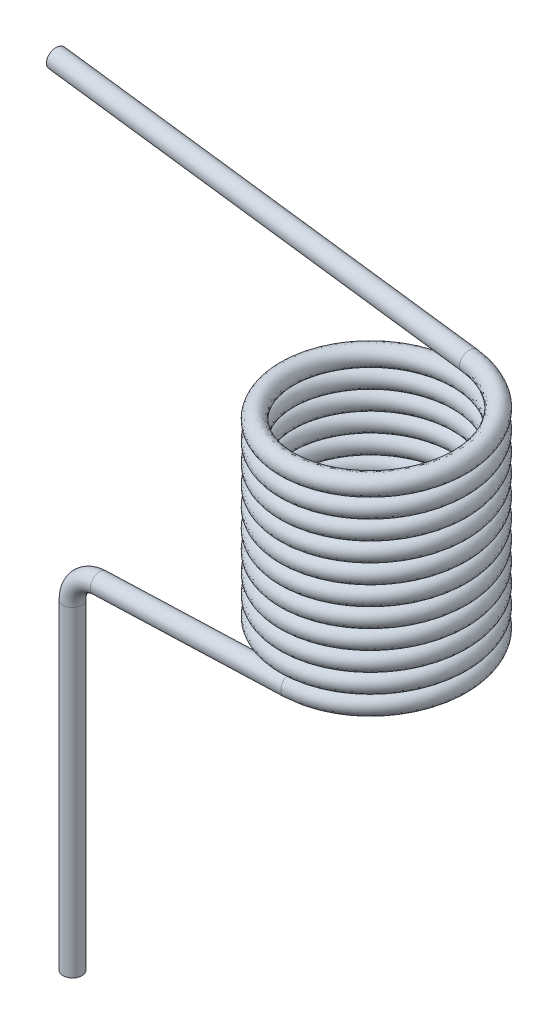
from build123d import *

# Parameters (mm, degrees)
SKETCH5_R = 0.127


with BuildPart() as part:
    # Sweep4: sweep along a curve in space
    with BuildLine() as sweep4_path:
        Line((-2.921, -4.7752, 1.1557), (-2.921, -0.470198244, 1.1557))
        ThreePointArc((-2.921, -0.470198244, 1.1557), (-2.814082298, -0.20554773, 1.1557), (-2.553336514, -0.089431731, 1.1557))
        Line((-2.553336514, -0.089431731, 1.1557), (0, 0, 1.1557))
        add(Edge.make_bspline(
            [(0, 0, 1.1557), (0.151002766, 0.005288938, 1.1557), (0.456339858, 0.015986032, 1.094955778), (0.841622203, 0.03193584, 0.835606243), (1.098293697, 0.047911326, 0.447870961), (1.186031785, 0.063879932, -0.008676931), (1.091593604, 0.079850382, -0.463891667), (0.829425347, 0.095820337, -0.847832309), (0.439824604, 0.111790425, -1.101508745), (-0.017353442, 0.127760477, -1.185945155), (-0.471864981, 0.143730539, -1.088168407), (-0.853877444, 0.159700599, -0.823201293), (-1.104696885, 0.175670659, -0.431754377), (-1.185786468, 0.191640719, 0.026028936), (-1.084687271, 0.207610778, 0.479813064), (-0.816932565, 0.223580838, 0.859876873), (-0.423661208, 0.239550898, 1.107825904), (0.034703081, 0.255520958, 1.185564316), (0.487735456, 0.271491018, 1.081148083), (0.865830285, 0.287461078, 0.810620114), (1.110895631, 0.303431138, 0.415545364), (1.185278714, 0.319401198, -0.043375369), (1.077551032, 0.335371257, -0.495631744), (0.804264279, 0.351341317, -0.871737358), (0.40740728, 0.367311377, -1.113905903), (-0.052045335, 0.383281437, -1.184929675), (-0.503501506, 0.399251497, -1.073896311), (-0.877597775, 0.415221557, -0.7978654), (-1.116856558, 0.431191617, -0.399247392), (-1.184517219, 0.447161677, 0.060712516), (-1.070184114, 0.463131737, 0.511344321), (-0.79142382, 0.479101796, 0.883411224), (-0.391066136, 0.495071856, 1.11974744), (0.069376448, 0.511041916, 1.184041368), (0.519159768, 0.527011976, 1.066414641), (0.889177392, 0.542982036, 0.784939882), (1.122578393, 0.558952096, 0.38286395), (1.183502147, 0.574922156, -0.078036666), (1.062588094, 0.590892216, -0.52694743), (0.778413934, 0.606862275, -0.894895971), (0.374641274, 0.622832335, -1.125349265), (-0.086692708, 0.638802395, -1.182899584), (-0.53470689, 0.654772455, -1.058704677), (-0.900566656, 0.670742515, -0.771846326), (-1.128059909, 0.686712575, -0.366398546), (-1.182233713, 0.702682635, 0.09534411), (-1.054764599, 0.718652695, 0.542437732), (-0.765237408, 0.734622754, 0.906189142), (-0.358136209, 0.750592814, 1.130710178), (0.103990409, 0.766562874, 1.181504569), (0.550139543, 0.782532934, 1.050768069), (0.911763129, 0.798502994, 0.758587535), (1.133299933, 0.814473054, 0.349854705), (1.180712191, 0.830443114, -0.112631143), (1.046715302, 0.846413174, -0.557811911), (0.751897063, 0.862383234, -0.917288319), (0.341554476, 0.878353293, -1.135829033), (-0.121265849, 0.894323353, -1.179856621), (-0.565454424, 0.910293413, -1.042606515), (-0.922764415, 0.926263473, -0.745166349), (-1.138297343, 0.942233533, -0.333235968), (-1.178937905, 0.958203593, 0.129894065), (-1.038441928, 0.974173653, 0.573066675), (-0.738395753, 0.990143713, 0.928191125), (-0.324899624, 1.006113772, 1.140704732), (0.138515328, 1.022083832, 1.177956093), (0.580648255, 1.038053892, 1.034221764), (0.933568158, 1.054023952, 0.731585639), (1.143051071, 1.069994012, 0.316545892), (1.176911236, 1.085964072, -0.147129179), (1.029946248, 1.101934132, -0.588198758), (0.72473637, 1.117904192, -0.938895226), (0.308175219, 1.133874251, -1.145336233), (-0.155735155, 1.149844311, -1.175803391), (-0.595717782, 1.165814371, -1.025615609), (-0.944172045, 1.181784431, -0.717848313), (-1.147560097, 1.197754491, -0.299788051), (-1.174632617, 1.213724551, 0.164332796), (-1.021230079, 1.229694611, 0.603204922), (-0.710921837, 1.245664671, 0.949398332), (-0.29138484, 1.261634731, 1.149722544), (0.172921642, 1.27760479, 1.173398977), (0.610659779, 1.29357485, 1.016789893), (0.954573807, 1.30954491, 0.703957313), (1.151823457, 1.32551497, 0.282966033), (1.172102536, 1.34148503, -0.181501233), (1.012295288, 1.35745509, -0.618081954), (0.696955113, 1.37342515, -0.959698194), (0.274532082, 1.38939521, -1.153862725), (-0.19007111, 1.405365269, -1.170743364), (-0.625471048, 1.421335329, -1.007746506), (-0.964771217, 1.437305389, -0.689915611), (-1.155840238, 1.453275449, -0.266083438), (-1.169321535, 1.469245509, 0.198630815), (-1.003143789, 1.485215569, 0.632826668), (-0.682839186, 1.501185629, 0.969792606), (-0.257620553, 1.517155689, 1.157755891), (0.207179889, 1.533125749, 1.167837123), (0.640148418, 1.549095808, 0.998487383), (0.974762091, 1.565065868, 0.675726215), (1.15960958, 1.581035928, 0.249143881), (1.166290209, 1.597005988, -0.215717874), (0.993777539, 1.612976048, -0.647435908), (0.668577079, 1.628946108, -0.979679408), (0.240653874, 1.644916168, -1.161401208), (-0.224244315, 1.660886228, -1.164680875), (-0.654688747, 1.676856287, -0.989014508), (-0.984544291, 1.692826347, -0.661392161), (-1.163130677, 1.708796407, -0.232150987), (-1.163009207, 1.724766467, 0.232758754), (-0.984198544, 1.740736527, 0.661906548), (-0.654171845, 1.756706587, 0.989356483), (-0.223635676, 1.772676647, 1.164797895), (0.241260735, 1.788646707, 1.161275295), (0.669088923, 1.804616766, 0.979329907), (0.994115723, 1.820586826, 0.646916518), (1.166402774, 1.836556886, 0.215108396), (1.159479231, 1.852526946, -0.249749805), (0.974408855, 1.868497006, -0.676235488), (0.639626568, 1.884467066, -0.998821759), (0.206569603, 1.900437126, -1.167945226), (-0.258225508, 1.916407186, -1.157621112), (-0.683345861, 1.932377246, -0.969435653), (-1.003474338, 1.948347305, -0.632302385), (-1.16942517, 1.964317365, -0.198019754), (-1.155701038, 1.980287425, 0.26668739), (-0.964410567, 1.996257485, 0.690419662), (-0.624944361, 2.012227545, 1.00807321), (-0.189459308, 2.028197605, 1.170842527), (0.275135, 2.044167665, 1.15371911), (0.697456511, 2.060137725, 0.959333866), (1.012618131, 2.076107784, 0.617552891), (1.17219722, 2.092077844, 0.180888722), (1.151675435, 2.108047904, -0.283567884), (0.954205822, 2.124017964, -0.704456033), (0.610128368, 2.139988024, -1.017108857), (0.172308454, 2.155958084, -1.173489177), (-0.291985592, 2.171928144, -1.149570123), (-0.711417852, 2.187898204, -0.949026708), (-1.021545146, 2.203868263, -0.602671192), (-1.174718329, 2.219838323, -0.163718965), (-1.147403285, 2.235808383, 0.300387672), (-0.943796802, 2.251778443, 0.718341596), (-0.595181761, 2.267748503, 1.025926763), (-0.155120713, 2.283718563, 1.17588461), (0.308773676, 2.299688623, 1.145175039), (0.725226894, 2.315658683, 0.938516385), (1.030253472, 2.331628743, 0.587660476), (1.176987958, 2.347598802, 0.146514159), (1.142885503, 2.363568862, -0.317143154), (0.933185738, 2.379538922, -0.732073378), (0.580107739, 2.395508982, -1.034525042), (0.137899764, 2.411479042, -1.178028313), (-0.325495659, 2.427449102, -1.140534799), (-0.738880682, 2.443419162, -0.927805147), (-1.038741244, 2.459389222, -0.572523955), (-1.179005621, 2.475359281, -0.129277989), (-1.138123054, 2.491329341, 0.333830744), (-0.922374903, 2.507299401, 0.74564844), (-0.564909518, 2.523269461, 1.042901854), (-0.120649338, 2.539239523, 1.179919824), (0.342148126, 2.555209575, 1.135650412), (0.752375678, 2.571179663, 0.916895233), (1.047008938, 2.587149618, 0.55726507), (1.180762331, 2.603120068, 0.112013394), (1.133148884, 2.619088674, -0.350444074), (0.911247459, 2.63506416, -0.759074301), (0.550035031, 2.651013968, -1.051016502), (0.251154047, 2.661711062, -1.138141454), (0.100725892, 2.667, -1.151302213)],
            knots=[0, 0, 0, 0, 0.005988024, 0.011976048, 0.017964072, 0.023952096, 0.02994012, 0.035928144, 0.041916168, 0.047904192, 0.053892216, 0.05988024, 0.065868263, 0.071856287, 0.077844311, 0.083832335, 0.089820359, 0.095808383, 0.101796407, 0.107784431, 0.113772455, 0.119760479, 0.125748503, 0.131736527, 0.137724551, 0.143712575, 0.149700599, 0.155688623, 0.161676647, 0.167664671, 0.173652695, 0.179640719, 0.185628743, 0.191616766, 0.19760479, 0.203592814, 0.209580838, 0.215568862, 0.221556886, 0.22754491, 0.233532934, 0.239520958, 0.245508982, 0.251497006, 0.25748503, 0.263473054, 0.269461078, 0.275449102, 0.281437126, 0.28742515, 0.293413174, 0.299401198, 0.305389222, 0.311377246, 0.317365269, 0.323353293, 0.329341317, 0.335329341, 0.341317365, 0.347305389, 0.353293413, 0.359281437, 0.365269461, 0.371257485, 0.377245509, 0.383233533, 0.389221557, 0.395209581, 0.401197605, 0.407185629, 0.413173653, 0.419161677, 0.425149701, 0.431137725, 0.437125749, 0.443113772, 0.449101796, 0.45508982, 0.461077844, 0.467065868, 0.473053892, 0.479041916, 0.48502994, 0.491017964, 0.497005988, 0.502994012, 0.508982036, 0.51497006, 0.520958084, 0.526946108, 0.532934132, 0.538922156, 0.54491018, 0.550898204, 0.556886228, 0.562874251, 0.568862275, 0.574850299, 0.580838323, 0.586826347, 0.592814371, 0.598802395, 0.604790419, 0.610778443, 0.616766467, 0.622754491, 0.628742515, 0.634730539, 0.640718563, 0.646706587, 0.652694611, 0.658682635, 0.664670659, 0.670658683, 0.676646707, 0.682634731, 0.688622754, 0.694610778, 0.700598802, 0.706586826, 0.71257485, 0.718562874, 0.724550898, 0.730538922, 0.736526946, 0.74251497, 0.748502994, 0.754491018, 0.760479042, 0.766467066, 0.77245509, 0.778443114, 0.784431138, 0.790419162, 0.796407186, 0.80239521, 0.808383234, 0.814371257, 0.820359281, 0.826347305, 0.832335329, 0.838323353, 0.844311377, 0.850299401, 0.856287425, 0.862275449, 0.868263473, 0.874251497, 0.880239521, 0.886227545, 0.892215569, 0.898203593, 0.904191617, 0.910179641, 0.916167665, 0.922155689, 0.928143713, 0.934131737, 0.94011976, 0.946107784, 0.952095808, 0.958083832, 0.964071856, 0.97005988, 0.976047904, 0.982035928, 0.988023952, 0.994011976, 1, 1, 1, 1], degree=3))
        Line((0.100725892, 2.667, -1.151302213), (-5.972076988, 2.880515072, -1.68260362))
    # Sketch5 → Sweep4 (sweep)
    with BuildSketch(Plane(origin=(-5.972076988, 2.880515072, -1.68260362), x_dir=(-0.06554337733977861, 0.4050497338324717, 0.9119423111190418), z_dir=(-0.995584203214185, 0.03500397378701607, -0.08710233136658467))):
        Circle(SKETCH5_R)
    sweep(path=sweep4_path.line, is_frenet=True)


solid = part.part
